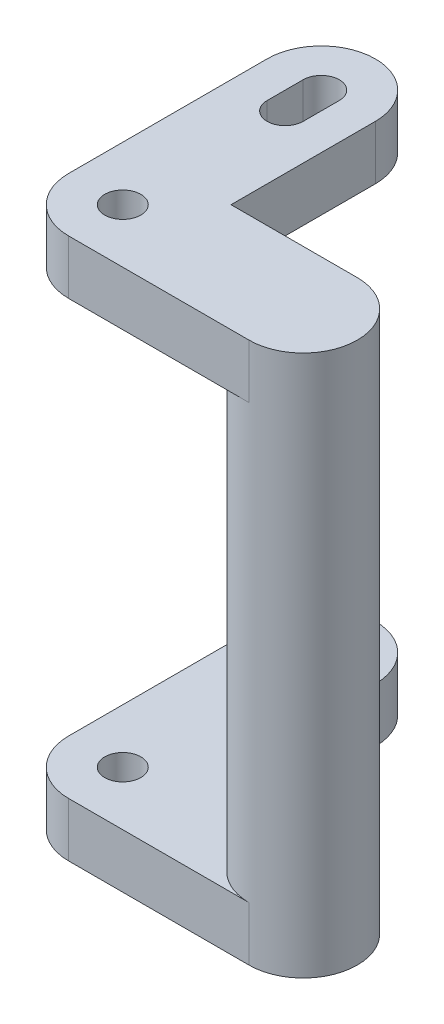
from build123d import *
from build123d.topology import SkipClean

# Parameters (mm, degrees)
SKETCH1_R           = 0.5
BOSS_EXTRUDE1_DEPTH = 1.5
SKETCH2_R           = 1.5
BOSS_EXTRUDE2_DEPTH = 12
SKETCH3_R           = 0.5
BOSS_EXTRUDE3_DEPTH = 1.5


with BuildPart() as part:
    # Sketch1 → Boss-Extrude1 (new body)
    with BuildSketch(Plane(origin=(0, 0, 0), x_dir=(1, 0, 0), z_dir=(0, 1, 0))):
        with BuildLine():
            Line((5, -1), (1.5, -1))
            Line((1.5, -1), (1.5, 2.5))
            Line((1.5, 2.5), (1.5, 3))
            ThreePointArc((1.5, 3), (0, 4.5), (-1.5, 3))
            Line((-1.5, 3), (-1.5, 2.5))
            Line((-1.5, 2.5), (-1.5, -2.5))
            ThreePointArc((-1.5, -2.5), (-1.060660172, -3.560660172), (0, -4))
            Line((0, -4), (5, -4))
            ThreePointArc((5, -4), (6.5, -2.5), (5, -1))
        make_face()
        with Locations(Location((0, -2.5, 0), (0, 0, 270))):
            Circle(SKETCH1_R, mode=Mode.SUBTRACT)
        with BuildLine():
            Line((-0.5, 3), (-0.5, 2))
            ThreePointArc((-0.5, 2), (0, 1.5), (0.5, 2))
            Line((0.5, 2), (0.5, 3))
            ThreePointArc((0.5, 3), (0, 3.5), (-0.5, 3))
        make_face(mode=Mode.SUBTRACT)
    extrude(amount=BOSS_EXTRUDE1_DEPTH)

    # Sketch2 → Boss-Extrude2 (add)
    with BuildSketch(Plane(origin=(0, 1.5, 0), x_dir=(1, 0, 0), z_dir=(0, 1, 0))):
        with Locations(Location((5, -2.5, 0), (0, 0, 270))):
            Circle(SKETCH2_R)
    extrude(amount=BOSS_EXTRUDE2_DEPTH)

    # Sketch3 → Boss-Extrude3 (add)
    with SkipClean():  # the faces are left unmerged after this step: merging them gives an invalid solid
        with BuildSketch(Plane(origin=(0, 13.5, 0), x_dir=(1, 0, 0), z_dir=(0, 1, 0))):
            with BuildLine():
                Line((1.5, -1), (5, -1))
                ThreePointArc((5, -1), (6.5, -2.5), (5, -4))
                Line((5, -4), (0, -4))
                ThreePointArc((0, -4), (-1.060660172, -3.560660172), (-1.5, -2.5))
                Line((-1.5, -2.5), (-1.5, 2.5))
                Line((-1.5, 2.5), (-1.5, 3))
                ThreePointArc((-1.5, 3), (0, 4.5), (1.5, 3))
                Line((1.5, 3), (1.5, 2.5))
                Line((1.5, 2.5), (1.5, -1))
            make_face()
            with Locations(Location((0, -2.5, 0), (0, 0, 270))):
                Circle(SKETCH3_R, mode=Mode.SUBTRACT)
            with BuildLine():
                Line((-0.5, 3), (-0.5, 2))
                ThreePointArc((-0.5, 2), (0, 1.5), (0.5, 2))
                Line((0.5, 2), (0.5, 3))
                ThreePointArc((0.5, 3), (0, 3.5), (-0.5, 3))
            make_face(mode=Mode.SUBTRACT)
        extrude(amount=BOSS_EXTRUDE3_DEPTH)


solid = part.part
